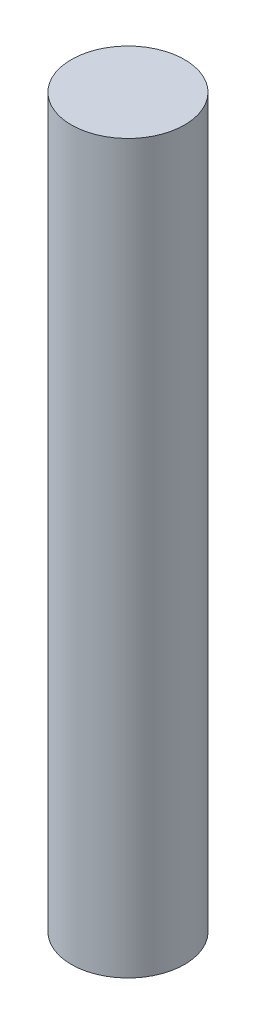
from build123d import *

# Parameters (mm, degrees)
SKETCH1_R           = 4
BOSS_EXTRUDE1_DEPTH = 25.675


with BuildPart() as part:
    # Sketch1 → Boss-Extrude1 (new body, symmetric)
    with BuildSketch(Plane(origin=(0, 0, 0), x_dir=(1, 0, 0), z_dir=(0, 1, 0))):
        Circle(SKETCH1_R)
    extrude(amount=BOSS_EXTRUDE1_DEPTH, both=True)


solid = part.part
